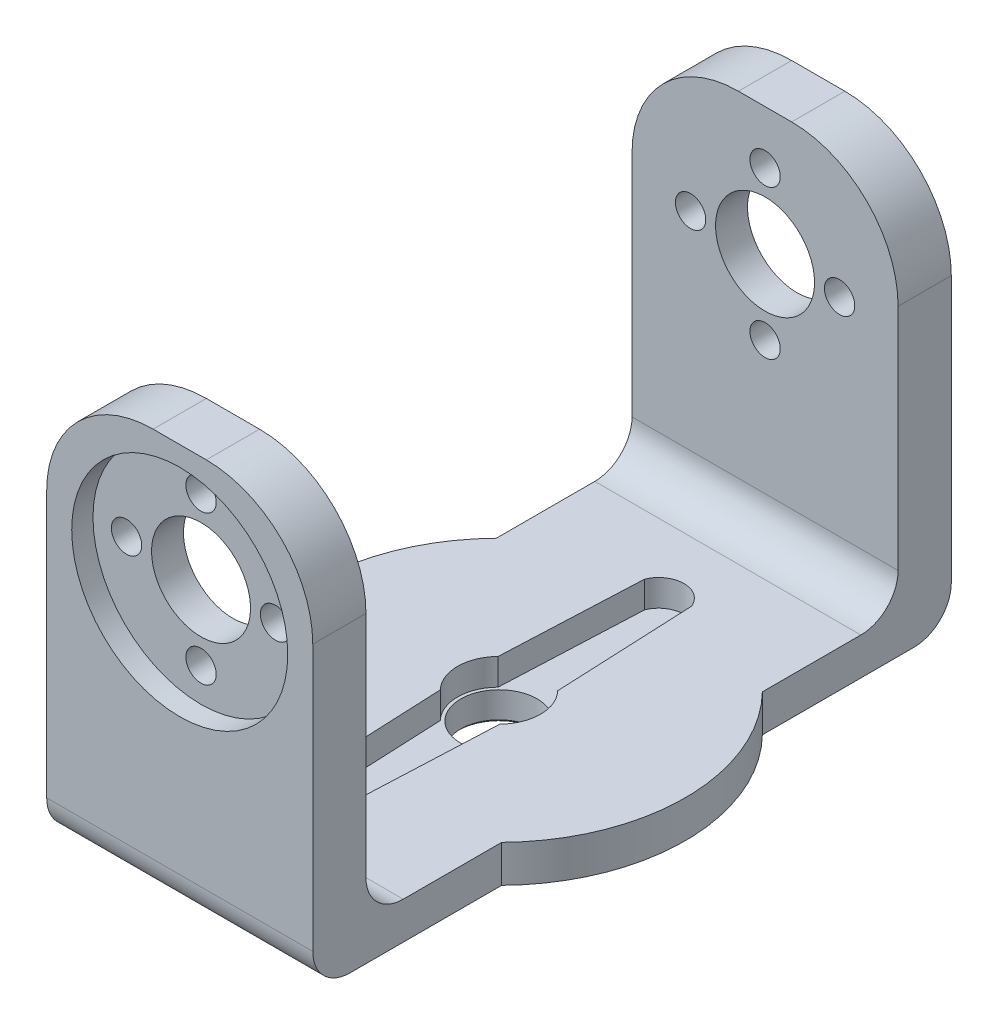
from build123d import *

# Parameters (mm, degrees)
CROQUIS1_R                   = 17.5
CROQUIS1_R_2                 = 1.65
SALIENTE_EXTRUIR1_DEPTH      = 3.5
CORTAR_EXTRUIR1_DEPTH        = 2.5
CROQUIS4_R                   = 3.6
CORTAR_EXTRUIR2_DEPTH        = 25.874685928
CORTAR_EXTRUIR2_DEPTH_BACK   = 25.874685928
CROQUIS5_R                   = 5.6
CROQUIS5_R_2                 = 3.6
SALIENTE_EXTRUIR2_DEPTH      = 1.7
SALIENTE_EXTRUIR3_REACH      = 52.742
SALIENTE_EXTRUIR3_END_RADIUS = 17.5
CROQUIS6_W                   = 25
CROQUIS6_H                   = 3.5
CROQUIS7_W                   = 25
CROQUIS7_H                   = 5
SALIENTE_EXTRUIR4_DEPTH      = 35
REDONDEO1_R                  = 3.5
REDONDEO1_OF_SIMETR_A1_R     = 3.5
CHAFL_N1_SIZE                = 0.254
CORTAR_EXTRUIR3_DEPTH        = 2.5
CROQUIS10_R                  = 10.15
CROQUIS10_R_2                = 1.425
CROQUIS10_R_3                = 1
CORTAR_EXTRUIR7_DEPTH        = 2
CORTAR_EXTRUIR8_REACH        = 71.379
CROQUIS11_R                  = 4.65
CORTAR_EXTRUIR9_REACH        = 73.781
CROQUIS13_R                  = 1.425
REDONDEO2_R                  = 10
CORTAR_EXTRUIR10_DEPTH       = 2.5


with BuildPart() as part:
    # Croquis1 → Saliente-Extruir1 (new body)
    with BuildSketch(Plane(origin=(0, 0, 0), x_dir=(1, 0, 0), z_dir=(0, 1, 0))):
        with Locations(Location((0, 0, 0), (0, 0, 270))):
            Circle(CROQUIS1_R)
        with Locations(Location((0, 0, 0), (0, 0, 270))):
            Circle(CROQUIS1_R_2, mode=Mode.SUBTRACT)
        with BuildLine():
            Line((-1.997159934, -12.106546701), (-2.53, -2.118749631))
            ThreePointArc((-2.53, -2.118749631), (-3.3, 0), (-2.53, 2.118749631))
            Line((-2.53, 2.118749631), (-1.997159934, 12.106546701))
            ThreePointArc((-1.997159934, 12.106546701), (0, 14), (1.997159934, 12.106546701))
            Line((1.997159934, 12.106546701), (2.53, 2.118749631))
            ThreePointArc((2.53, 2.118749631), (3.3, 0), (2.53, -2.118749631))
            Line((2.53, -2.118749631), (1.997159934, -12.106546701))
            ThreePointArc((1.997159934, -12.106546701), (0, -14), (-1.997159934, -12.106546701))
        make_face()
        with Locations(Location((0, 0, 0), (0, 0, 270))):
            Circle(CROQUIS1_R_2, mode=Mode.SUBTRACT)
    extrude(amount=SALIENTE_EXTRUIR1_DEPTH)

    # Croquis2 → Cortar-Extruir1 (cut)
    with BuildSketch(Plane(origin=(0, 3.5, 0), x_dir=(1, 0, 0), z_dir=(0, 1, 0))):
        with BuildLine():
            Line((-1.997159934, -12.106546701), (-2.53, -2.118749631))
            ThreePointArc((-2.53, -2.118749631), (-3.3, 0), (-2.53, 2.118749631))
            Line((-2.53, 2.118749631), (-1.997159934, 12.106546701))
            ThreePointArc((-1.997159934, 12.106546701), (0, 14), (1.997159934, 12.106546701))
            Line((1.997159934, 12.106546701), (2.53, 2.118749631))
            ThreePointArc((2.53, 2.118749631), (3.3, 0), (2.53, -2.118749631))
            Line((2.53, -2.118749631), (1.997159934, -12.106546701))
            ThreePointArc((1.997159934, -12.106546701), (0, -14), (-1.997159934, -12.106546701))
        make_face()
    extrude(amount=-CORTAR_EXTRUIR1_DEPTH, mode=Mode.SUBTRACT)

    # Croquis4 → Cortar-Extruir2 (cut, two sides)
    with BuildSketch(Plane(origin=(0, 1, 0), x_dir=(1, 0, 0), z_dir=(0, 1, 0))) as cortar_extruir2_sk:
        with Locations(Location((0, 0, 0), (0, 0, 270))):
            Circle(CROQUIS4_R)
    extrude(amount=CORTAR_EXTRUIR2_DEPTH, mode=Mode.SUBTRACT)
    extrude(cortar_extruir2_sk.sketch, amount=-CORTAR_EXTRUIR2_DEPTH_BACK, mode=Mode.SUBTRACT)

    # Croquis5 → Saliente-Extruir2 (add)
    with BuildSketch(Plane.XZ):
        with Locations(Location((0, 0, 0), (0, 0, 90))):
            Circle(CROQUIS5_R)
        with Locations(Location((0, 0, 0), (0, 0, 90))):
            Circle(CROQUIS5_R_2, mode=Mode.SUBTRACT)
    extrude(amount=SALIENTE_EXTRUIR2_DEPTH)

    # Saliente-Extruir3: up to this cylinder (the profile starts outside it)
    saliente_extruir3_end = Plane(origin=(0, 1.75, 0), z_dir=(0, -1, 0)) * Cylinder(SALIENTE_EXTRUIR3_END_RADIUS, 141.484, mode=Mode.PRIVATE)
    # Croquis6 → Saliente-Extruir3 (add, up to the surface)
    with BuildSketch(Plane.XY.offset(30), mode=Mode.PRIVATE) as saliente_extruir3_sk1:
        with Locations((0, 1.75)):
            Rectangle(CROQUIS6_W, CROQUIS6_H)
    saliente_extruir3_tool1 = extrude(saliente_extruir3_sk1.sketch, amount=-SALIENTE_EXTRUIR3_REACH, mode=Mode.PRIVATE) - saliente_extruir3_end
    saliente_extruir3 = saliente_extruir3_tool1.solids().sort_by_distance((0, 1.75, 30))[0]
    add(saliente_extruir3)

    # Croquis7 → Saliente-Extruir4 (add)
    with BuildSketch(Plane(origin=(0, 3.5, 0), x_dir=(1, 0, 0), z_dir=(0, 1, 0))):
        with Locations((0, -27.5)):
            Rectangle(CROQUIS7_W, CROQUIS7_H)
    saliente_extruir4 = extrude(amount=SALIENTE_EXTRUIR4_DEPTH)

    # Redondeo1
    redondeo1_edges = [part.edges().sort_by_distance(p)[0] for p in [
        (0, 0, 30),
        (0, 3.5, 25),
    ]]
    fillet(redondeo1_edges, radius=REDONDEO1_R)

    # Simetría1: Saliente-Extruir3, Saliente-Extruir4 across plane
    add(saliente_extruir3.mirror(Plane.XY))
    add(saliente_extruir4.mirror(Plane.XY))

    # Redondeo1 of Simetría1
    redondeo1_of_simetr_a1_edges = [part.edges().sort_by_distance(p)[0] for p in [
        (0, 0, -30),
        (0, 3.5, -25),
    ]]
    fillet(redondeo1_of_simetr_a1_edges, radius=REDONDEO1_OF_SIMETR_A1_R)

    # Chaflán1
    chafl_n1_edges = [part.edges().sort_by_distance(p)[0] for p in [
        (0, -1.7, -3.6),
    ]]
    chamfer(chafl_n1_edges, length=CHAFL_N1_SIZE)

    # Croquis8 → Cortar-Extruir3 (cut)
    with BuildSketch(Plane(origin=(0, 3.5, 0), x_dir=(1, 0, 0), z_dir=(0, 1, 0))):
        with BuildLine():
            Line((-2.795512377, -2.719395254), (-2.374256235, -12.106546701))
            ThreePointArc((-2.374256235, -12.106546701), (0, -14.376645718), (2.374256235, -12.106546701))
            Line((2.374256235, -12.106546701), (2.795512377, -2.719395254))
            ThreePointArc((2.795512377, -2.719395254), (3.9, 0), (2.795512377, 2.719395254))
            Line((2.795512377, 2.719395254), (2.374256235, 12.106546701))
            ThreePointArc((2.374256235, 12.106546701), (0, 14.376645718), (-2.374256235, 12.106546701))
            Line((-2.374256235, 12.106546701), (-2.795512377, 2.719395254))
            ThreePointArc((-2.795512377, 2.719395254), (-3.9, 0), (-2.795512377, -2.719395254))
        make_face()
    extrude(amount=-CORTAR_EXTRUIR3_DEPTH, mode=Mode.SUBTRACT)

    # Croquis10 → Cortar-Extruir7 (cut)
    with BuildSketch(Plane(origin=(0, 0, 30), x_dir=(-1, 0, 0), z_dir=(0, 0, -1))):
        with Locations(Location((0, 26.5, 0), (0, 0, 180))):
            Circle(CROQUIS10_R)
        with Locations((-7, 26.5)):
            Circle(CROQUIS10_R_2, mode=Mode.SUBTRACT)
        with Locations((0, 33.5)):
            Circle(CROQUIS10_R_2, mode=Mode.SUBTRACT)
        with Locations((0, 26.5)):
            Circle(CROQUIS10_R_3, mode=Mode.SUBTRACT)
        with Locations((7, 26.5)):
            Circle(CROQUIS10_R_2, mode=Mode.SUBTRACT)
        with Locations((0, 19.5)):
            Circle(CROQUIS10_R_2, mode=Mode.SUBTRACT)
        with Locations((7, 26.5)):
            Circle(CROQUIS10_R_2)
        with Locations((0, 26.5)):
            Circle(CROQUIS10_R_3)
        with Locations((0, 33.5)):
            Circle(CROQUIS10_R_2)
        with Locations((-7, 26.5)):
            Circle(CROQUIS10_R_2)
        with Locations((0, 19.5)):
            Circle(CROQUIS10_R_2)
    cortar_extruir7 = extrude(amount=CORTAR_EXTRUIR7_DEPTH, mode=Mode.SUBTRACT)

    # Croquis11 → Cortar-Extruir8 (cut, up to next)
    with BuildSketch(Plane(origin=(0, 0, 25), x_dir=(-1, 0, 0), z_dir=(0, 0, -1)), mode=Mode.PRIVATE) as cortar_extruir8_sk1:
        with Locations((0, 26.5)):
            Circle(CROQUIS11_R)
    cortar_extruir8_tool1 = extrude(cortar_extruir8_sk1.sketch, amount=-CORTAR_EXTRUIR8_REACH, mode=Mode.PRIVATE) & part.part
    cortar_extruir8 = cortar_extruir8_tool1.solids().sort_by_distance((0, 26.5, 25))[0]
    add(cortar_extruir8, mode=Mode.SUBTRACT)

    # Croquis13 → Cortar-Extruir9 (cut, up to next)
    with BuildSketch(Plane.XY.offset(28), mode=Mode.PRIVATE) as cortar_extruir9_sk1:
        with Locations((0, 19.5)):
            Circle(CROQUIS13_R)
    cortar_extruir9_tool1 = extrude(cortar_extruir9_sk1.sketch, amount=-CORTAR_EXTRUIR9_REACH, mode=Mode.PRIVATE) & part.part
    # Croquis13 → Cortar-Extruir9 (cut, up to next)
    with BuildSketch(Plane.XY.offset(28), mode=Mode.PRIVATE) as cortar_extruir9_sk2:
        with Locations((7, 26.5)):
            Circle(CROQUIS13_R)
    cortar_extruir9_tool2 = extrude(cortar_extruir9_sk2.sketch, amount=-CORTAR_EXTRUIR9_REACH, mode=Mode.PRIVATE) & part.part
    # Croquis13 → Cortar-Extruir9 (cut, up to next)
    with BuildSketch(Plane.XY.offset(28), mode=Mode.PRIVATE) as cortar_extruir9_sk3:
        with Locations((0, 33.5)):
            Circle(CROQUIS13_R)
    cortar_extruir9_tool3 = extrude(cortar_extruir9_sk3.sketch, amount=-CORTAR_EXTRUIR9_REACH, mode=Mode.PRIVATE) & part.part
    # Croquis13 → Cortar-Extruir9 (cut, up to next)
    with BuildSketch(Plane.XY.offset(28), mode=Mode.PRIVATE) as cortar_extruir9_sk4:
        with Locations((-7, 26.5)):
            Circle(CROQUIS13_R)
    cortar_extruir9_tool4 = extrude(cortar_extruir9_sk4.sketch, amount=-CORTAR_EXTRUIR9_REACH, mode=Mode.PRIVATE) & part.part
    cortar_extruir9_1 = cortar_extruir9_tool1.solids().sort_by_distance((0, 19.5, 28))[0]
    add(cortar_extruir9_1, mode=Mode.SUBTRACT)
    cortar_extruir9_2 = cortar_extruir9_tool2.solids().sort_by_distance((7, 26.5, 28))[0]
    add(cortar_extruir9_2, mode=Mode.SUBTRACT)
    cortar_extruir9_3 = cortar_extruir9_tool3.solids().sort_by_distance((0, 33.5, 28))[0]
    add(cortar_extruir9_3, mode=Mode.SUBTRACT)
    cortar_extruir9_4 = cortar_extruir9_tool4.solids().sort_by_distance((-7, 26.5, 28))[0]
    add(cortar_extruir9_4, mode=Mode.SUBTRACT)
    cortar_extruir9 = cortar_extruir9_1 + cortar_extruir9_2 + cortar_extruir9_3 + cortar_extruir9_4  # Cortar-Extruir9 as one shape, for the pattern or mirror that repeats it

    # Simetría2: Cortar-Extruir7, Cortar-Extruir8, Cortar-Extruir9 across plane
    add(cortar_extruir7.mirror(Plane.XY), mode=Mode.SUBTRACT)
    add(cortar_extruir8.mirror(Plane.XY), mode=Mode.SUBTRACT)
    add(cortar_extruir9.mirror(Plane.XY), mode=Mode.SUBTRACT)

    # Redondeo2
    redondeo2_edges = [part.edges().sort_by_distance(p)[0] for p in [
        (12.5, 38.5, -27.5),
        (-12.5, 38.5, -27.5),
        (12.5, 38.5, 27.5),
        (-12.5, 38.5, 27.5),
    ]]
    fillet(redondeo2_edges, radius=REDONDEO2_R)

    # Croquis15 → Cortar-Extruir10 (cut)
    with BuildSketch(Plane(origin=(0, 3.5, 0), x_dir=(1, 0, 0), z_dir=(0, 1, 0))):
        with BuildLine():
            Line((2.374256235, 12.106546701), (2.20456569, 15.887882306))
            ThreePointArc((2.20456569, 15.887882306), (0, 17.376645718), (-2.20456569, 15.887882306))
            Line((-2.20456569, 15.887882306), (-2.374256235, 12.106546701))
            ThreePointArc((-2.374256235, 12.106546701), (0, 14.376645718), (2.374256235, 12.106546701))
        make_face()
        with BuildLine():
            Line((2.374256235, -12.106546701), (2.20456569, -15.887882306))
            ThreePointArc((2.20456569, -15.887882306), (0, -17.376645718), (-2.20456569, -15.887882306))
            Line((-2.20456569, -15.887882306), (-2.374256235, -12.106546701))
            ThreePointArc((-2.374256235, -12.106546701), (0, -14.376645718), (2.374256235, -12.106546701))
        make_face()
    extrude(amount=-CORTAR_EXTRUIR10_DEPTH, mode=Mode.SUBTRACT)


solid = part.part
